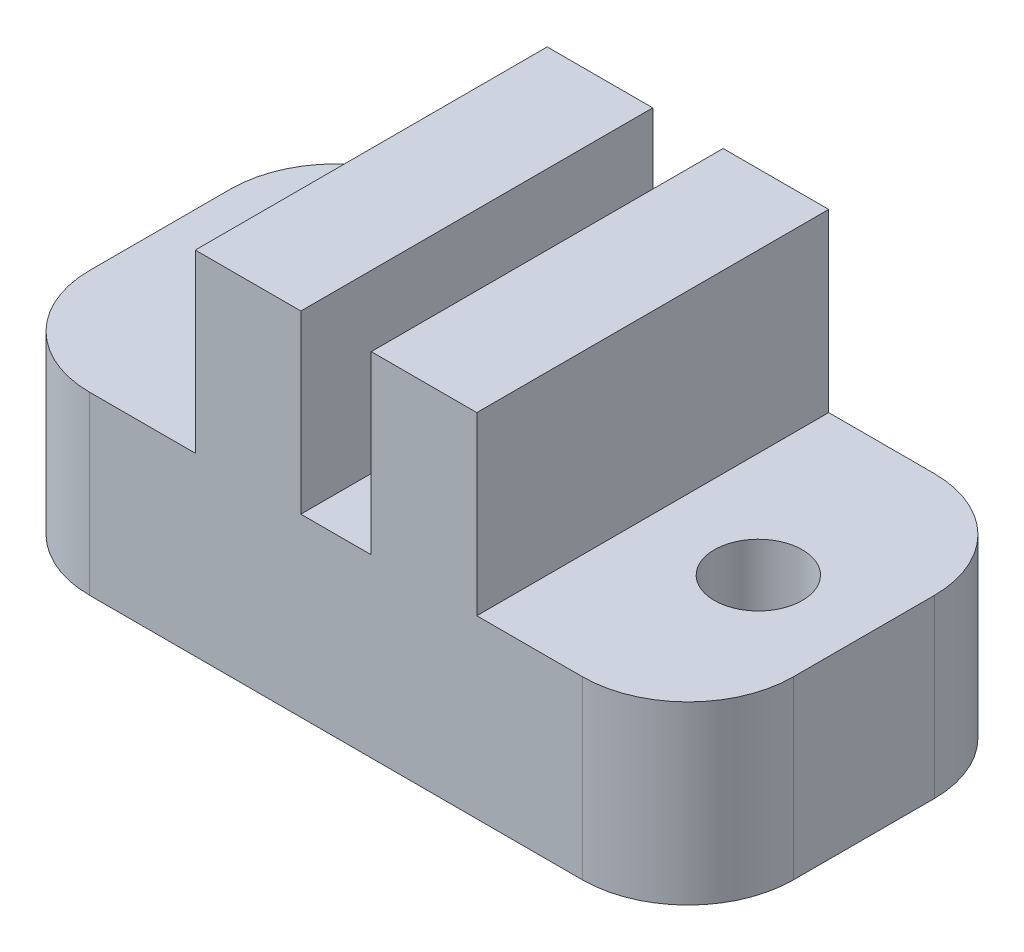
from build123d import *

# Parameters (mm, degrees)
SKETCH1_W           = 20
SKETCH1_H           = 10
SKETCH1_R           = 1.25
BOSS_EXTRUDE1_DEPTH = 5
SKETCH2_W           = 3
SKETCH2_H           = 10
BOSS_EXTRUDE2_DEPTH = 5
FILLET1_R           = 3


with BuildPart() as part:
    # Sketch1 → Boss-Extrude1 (new body)
    with BuildSketch(Plane(origin=(0, 0, 0), x_dir=(1, 0, 0), z_dir=(0, 1, 0))):
        with Locations((10, 5)):
            Rectangle(SKETCH1_W, SKETCH1_H)
        with Locations((3, 5)):
            Circle(SKETCH1_R, mode=Mode.SUBTRACT)
        with Locations((17, 5)):
            Circle(SKETCH1_R, mode=Mode.SUBTRACT)
    extrude(amount=BOSS_EXTRUDE1_DEPTH)

    # Sketch2 → Boss-Extrude2 (add)
    with BuildSketch(Plane(origin=(0, 5, 0), x_dir=(1, 0, 0), z_dir=(0, 1, 0))):
        with Locations((7.5, 5)):
            Rectangle(SKETCH2_W, SKETCH2_H)
        with Locations((12.5, 5)):
            Rectangle(SKETCH2_W, SKETCH2_H)
    extrude(amount=BOSS_EXTRUDE2_DEPTH)

    # Fillet1
    fillet1_edges = [part.edges().sort_by_distance(p)[0] for p in [
        (0, 2.5, -10),
        (20, 2.5, -10),
        (0, 2.5, 0),
        (20, 2.5, 0),
    ]]
    fillet(fillet1_edges, radius=FILLET1_R)


solid = part.part
